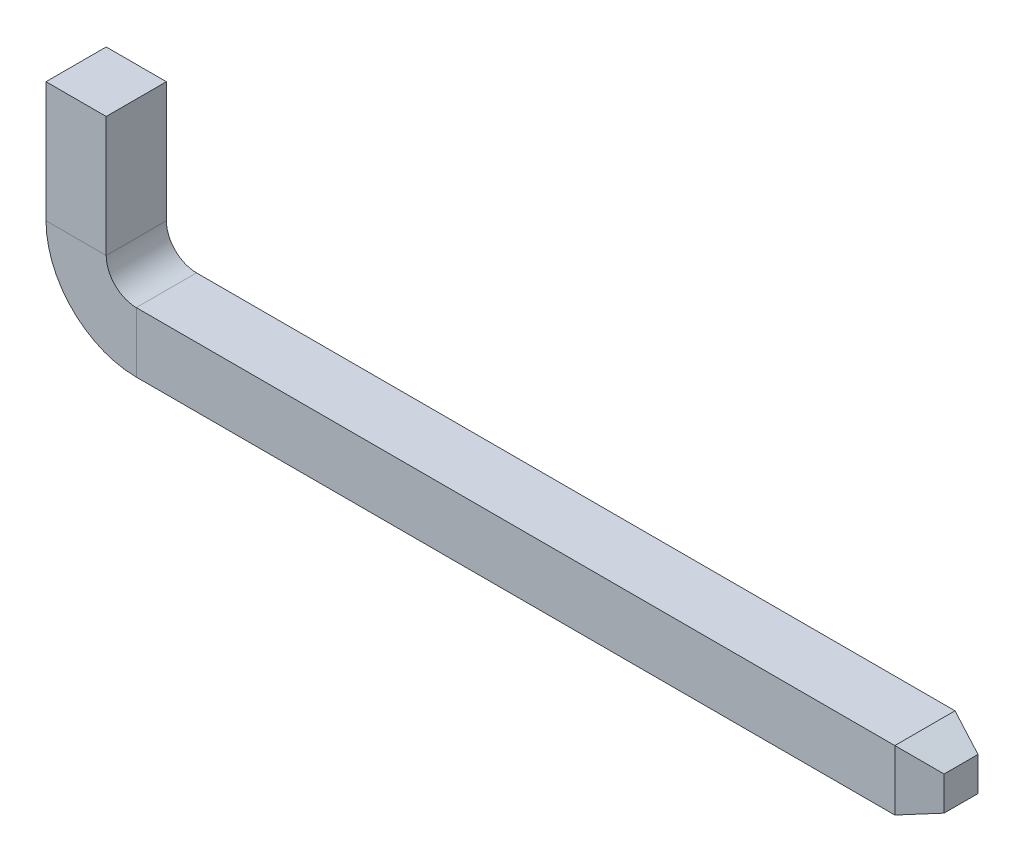
from build123d import *

# Parameters (mm, degrees)
SKETCH1_W           = 0.5
SKETCH1_H           = 0.5
SKETCH4_W           = 0.5
SKETCH4_H           = 0.5
BOSS_EXTRUDE1_DEPTH = 0.3
BOSS_EXTRUDE1_TAPER = 20


with BuildPart() as part:
    # Sweep1: sweep along a path in Sketch2
    with BuildLine(Plane.XY) as sweep1_path:
        Line((0, 0), (0, -1))
        ThreePointArc((0, -1), (0.146446609, -1.353553391), (0.5, -1.5))
        Line((0.5, -1.5), (6.8, -1.5))
    # Sketch1 → Sweep1 (sweep)
    with BuildSketch(Plane(origin=(0, 0, 0), x_dir=(1, 0, 0), z_dir=(0, 1, 0))):
        Rectangle(SKETCH1_W, SKETCH1_H)
    sweep(path=sweep1_path.line)

    # Sketch4 → Boss-Extrude1 (add)
    with BuildSketch(Plane(origin=(6.8, 0, 0), x_dir=(0, 0, -1), z_dir=(1, 0, 0))):
        with Locations((0, -1.5)):
            Rectangle(SKETCH4_W, SKETCH4_H)
    extrude(amount=BOSS_EXTRUDE1_DEPTH, taper=BOSS_EXTRUDE1_TAPER)


solid = part.part
